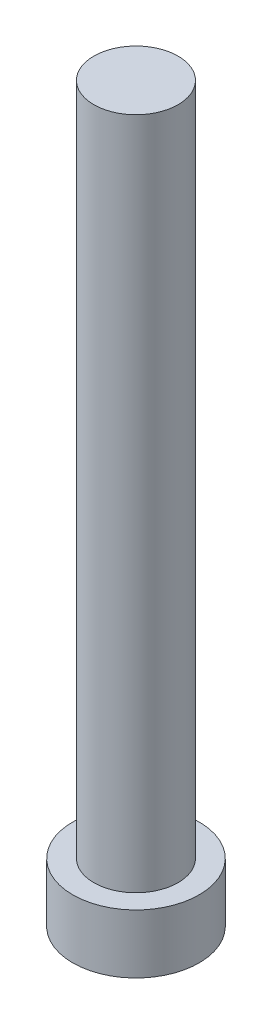
from build123d import *

# Parameters (mm, degrees)
SKETCH1_R           = 3.75
BOSS_EXTRUDE1_DEPTH = 3.5
SKETCH2_R           = 2.5
BOSS_EXTRUDE2_DEPTH = 40


with BuildPart() as part:
    # Sketch1 → Boss-Extrude1 (new body)
    with BuildSketch(Plane(origin=(0, 0, 0), x_dir=(1, 0, 0), z_dir=(0, 1, 0))):
        Circle(SKETCH1_R)
    extrude(amount=BOSS_EXTRUDE1_DEPTH)

    # Sketch2 → Boss-Extrude2 (add)
    with BuildSketch(Plane(origin=(0, 3.5, 0), x_dir=(1, 0, 0), z_dir=(0, 1, 0))):
        Circle(SKETCH2_R)
    extrude(amount=BOSS_EXTRUDE2_DEPTH)


solid = part.part
